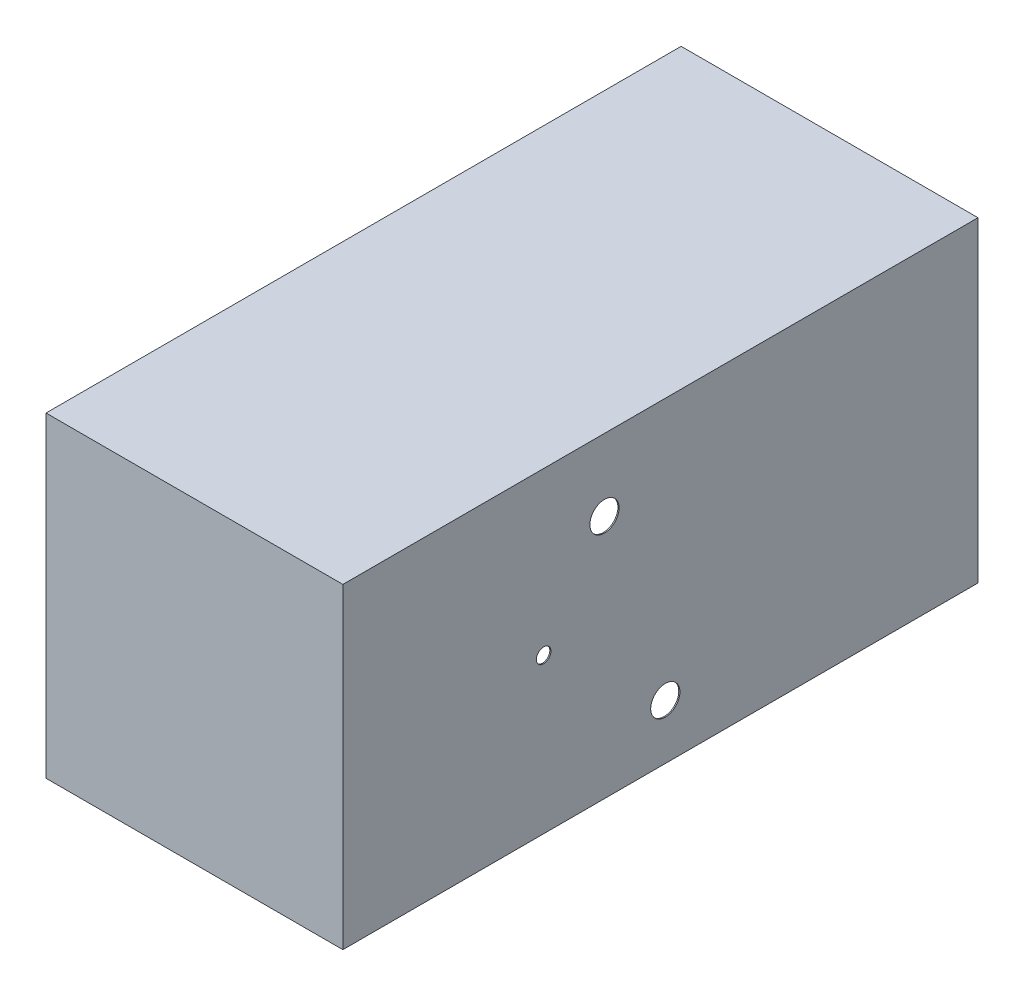
from build123d import *

# Parameters (mm, degrees)
SKETCH3_W           = 610
SKETCH3_H           = 1305
SKETCH3_W_2         = 605.325670498
SKETCH3_H_2         = 1295
BOSS_EXTRUDE2_DEPTH = 640
SKETCH4_R           = 30
SKETCH4_R_2         = 15
CUT_EXTRUDE1_DEPTH  = 640
SKETCH5_W           = 610
SKETCH5_H           = 1305
BOSS_EXTRUDE3_DEPTH = 10


with BuildPart() as part:
    # Sketch3 → Boss-Extrude2 (new body)
    with BuildSketch(Plane(origin=(0, 0, 0), x_dir=(1, 0, 0), z_dir=(0, 1, 0))):
        Rectangle(SKETCH3_W, SKETCH3_H)
        Rectangle(SKETCH3_W_2, SKETCH3_H_2, mode=Mode.SUBTRACT)
    extrude(amount=BOSS_EXTRUDE2_DEPTH)

    # Sketch4 → Cut-Extrude1 (cut)
    with BuildSketch(Plane(origin=(305, 0, 0), x_dir=(0, 0, -1), z_dir=(1, 0, 0))):
        with Locations((-115, 502.5)):
            Circle(SKETCH4_R)
        with Locations((10, 112.5)):
            Circle(SKETCH4_R)
        with Locations((-240, 317.5)):
            Circle(SKETCH4_R_2)
    extrude(amount=-CUT_EXTRUDE1_DEPTH, mode=Mode.SUBTRACT)

    # Sketch5 → Boss-Extrude3 (add)
    with BuildSketch(Plane(origin=(0, 640, 0), x_dir=(1, 0, 0), z_dir=(0, 1, 0))):
        Rectangle(SKETCH5_W, SKETCH5_H)
    extrude(amount=BOSS_EXTRUDE3_DEPTH)


solid = part.part
